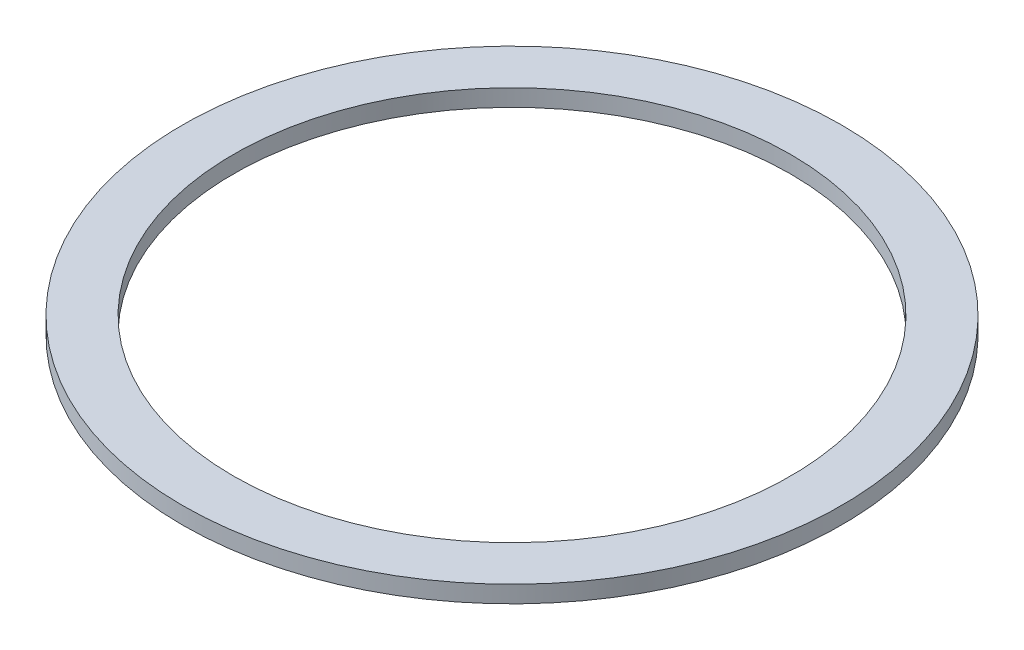
from build123d import *

# Parameters (mm, degrees)
SKETCH1_R           = 19.4
SKETCH1_R_2         = 16.4
BOSS_EXTRUDE1_DEPTH = 1


with BuildPart() as part:
    # Sketch1 → Boss-Extrude1 (new body)
    with BuildSketch(Plane(origin=(0, 0, 0), x_dir=(1, 0, 0), z_dir=(0, 1, 0))):
        Circle(SKETCH1_R)
        Circle(SKETCH1_R_2, mode=Mode.SUBTRACT)
    extrude(amount=BOSS_EXTRUDE1_DEPTH)


solid = part.part
